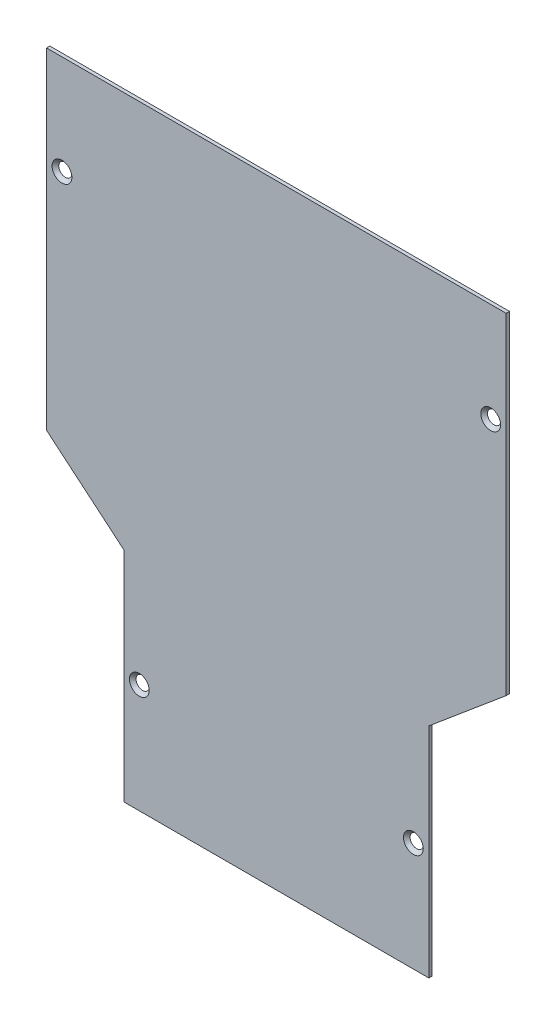
from build123d import *

# Parameters (mm, degrees)
RESSALTO_EXTRUS_O1_DEPTH                     = 1.5
ESCAREADO_PARA_PARAFUSO_ALLEN_SEXTAV_2_COUNT = 2
ESCAREADO_PARA_PARAFUSO_ALLEN_SEXTAV_2_PITCH = 194
ESCAREADO_PARA_PARAFUSO_ALLEN_SEXTAV_3_COUNT = 2
ESCAREADO_PARA_PARAFUSO_ALLEN_SEXTAV_3_PITCH = 242.881337709
ESCAREADO_PARA_PARAFUSO_ALLEN_SEXTAV_4_COUNT = 2
ESCAREADO_PARA_PARAFUSO_ALLEN_SEXTAV_4_PITCH = 186.909989587


with BuildPart() as part:
    # Esboço1 → Ressalto-extrusão1 (new body)
    with BuildSketch(Plane.XY):
        Polygon((100.860947645, 140.996609125), (-107.139052355, 140.996609125), (-107.139052355, -8.842442963), (-72.139052355, -38.210930054), (-72.139052355, -137.003390875), (65.860947645, -137.003390875), (65.860947645, -38.210930054), (100.860947645, -8.842442963), align=None)
    extrude(amount=RESSALTO_EXTRUS_O1_DEPTH)

    # Esboço3 → Escareado para parafuso Allen sextavado escareado de M41 (revolve, cut)
    with BuildSketch(Plane(origin=(-100.139052355, 95.996609125, 1.5), x_dir=(0, -1, 0), z_dir=(1, 0, 0))):
        Polygon((0, 0), (0, 1.5), (2.25, 1.5), (2.25, 2.23), (4.48, 0), align=None)
    escareado_para_parafuso_allen_sextavado = revolve(axis=Axis((-100.139052355, 95.996609125, 7.85), (0, 0, -1)), mode=Mode.SUBTRACT)

    # Escareado para parafuso Allen sextav 2: Escareado para parafuso Allen sextavado escareado de M41 ×2
    with Locations(*[(i * ESCAREADO_PARA_PARAFUSO_ALLEN_SEXTAV_2_PITCH, 0, 0) for i in range(1, ESCAREADO_PARA_PARAFUSO_ALLEN_SEXTAV_2_COUNT)]):
        add(escareado_para_parafuso_allen_sextavado, mode=Mode.SUBTRACT)

    # Escareado para parafuso Allen sextav 3: Escareado para parafuso Allen sextavado escareado de M41 ×2
    with Locations(*[Vector(0.654640663, -0.755940211, 0) * (i * ESCAREADO_PARA_PARAFUSO_ALLEN_SEXTAV_3_PITCH) for i in range(1, ESCAREADO_PARA_PARAFUSO_ALLEN_SEXTAV_3_COUNT)]):
        add(escareado_para_parafuso_allen_sextavado, mode=Mode.SUBTRACT)

    # Escareado para parafuso Allen sextav 4: Escareado para parafuso Allen sextavado escareado de M41 ×2
    with Locations(*[Vector(0.187255909, -0.982311165, 0) * (i * ESCAREADO_PARA_PARAFUSO_ALLEN_SEXTAV_4_PITCH) for i in range(1, ESCAREADO_PARA_PARAFUSO_ALLEN_SEXTAV_4_COUNT)]):
        add(escareado_para_parafuso_allen_sextavado, mode=Mode.SUBTRACT)


solid = part.part
